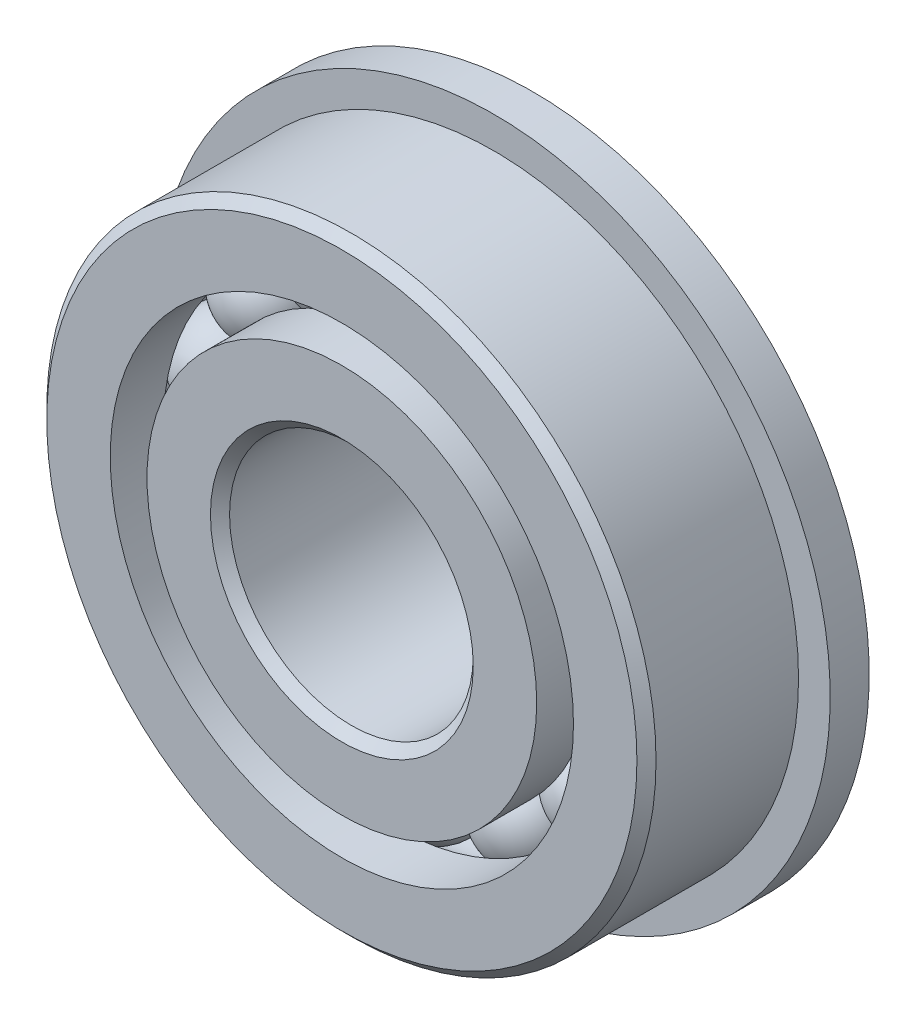
from build123d import *

# Parameters (mm, degrees)
SKETCH5_W         = 1.016
SKETCH5_H         = 1.901099286
CIRPATTERN1_COUNT = 14


with BuildPart() as part:
    # Sketch1 → Revolve1 (revolve)
    with BuildSketch(Plane(origin=(0, 0, 0), x_dir=(0, 0, -1), z_dir=(1, 0, 0))):
        with BuildLine():
            Line((2.24028, 7.9375), (-2.24028, 7.9375))
            Line((-2.24028, 7.9375), (-2.4892, 7.68858))
            Line((-2.4892, 7.68858), (-2.4892, 6.035221429))
            Line((-2.4892, 6.035221429), (-1.106311111, 6.035221429))
            ThreePointArc((-1.106311111, 6.035221429), (0, 6.76179465), (1.106311111, 6.035221429))
            Line((1.106311111, 6.035221429), (2.4892, 6.035221429))
            Line((2.4892, 6.035221429), (2.4892, 7.68858))
            Line((2.4892, 7.68858), (2.24028, 7.9375))
        make_face()
    revolve(axis=Axis((0, 0, 2.4892), (0, 0, -1)))

    # Sketch5 → Revolve5 (revolve)
    with BuildSketch(Plane(origin=(0, 0, 0), x_dir=(0, 0, -1), z_dir=(1, 0, 0))):
        with Locations((1.9812, 7.812450357)):
            Rectangle(SKETCH5_W, SKETCH5_H)
    revolve(axis=Axis((0, 0, -2.4892), (0, 0, 1)))


with BuildPart() as body_2:
    # Sketch3 → Revolve3 (revolve)
    with BuildSketch(Plane(origin=(0, 0, 0), x_dir=(0, 0, -1), z_dir=(1, 0, 0))):
        with BuildLine():
            Line((-1.106311111, 5.077278571), (-2.4892, 5.077278571))
            Line((-2.4892, 5.077278571), (-2.4892, 3.42392))
            Line((-2.4892, 3.42392), (-2.24028, 3.175))
            Line((-2.24028, 3.175), (2.24028, 3.175))
            Line((2.24028, 3.175), (2.4892, 3.42392))
            Line((2.4892, 3.42392), (2.4892, 5.077278571))
            Line((2.4892, 5.077278571), (1.106311111, 5.077278571))
            ThreePointArc((1.106311111, 5.077278571), (0, 4.35070535), (-1.106311111, 5.077278571))
        make_face()
    revolve(axis=Axis((0, 0, 2.4892), (0, 0, -1)))


with BuildPart() as body_3:
    # Sketch4 → Revolve4 (revolve)
    with BuildSketch(Plane(origin=(0, 0, 0), x_dir=(0, 0, -1), z_dir=(1, 0, 0))):
        with BuildLine():
            Line((-1.20554465, 5.55625), (1.20554465, 5.55625))
            ThreePointArc((1.20554465, 5.55625), (0, 6.76179465), (-1.20554465, 5.55625))
        make_face()
    revolve(axis=Axis((0, 5.55625, 1.20554465), (0, 0, -1)))


with BuildPart() as cirpattern1_1:
    # CirPattern1: pattern copy
    add(body_3.part.rotate(Axis((0, 0, -2.4892), (0, 0, 1)), 1 * 360 / CIRPATTERN1_COUNT))


with BuildPart() as cirpattern1_2:
    # CirPattern1: pattern copy
    add(body_3.part.rotate(Axis((0, 0, -2.4892), (0, 0, 1)), 2 * 360 / CIRPATTERN1_COUNT))


with BuildPart() as cirpattern1_3:
    # CirPattern1: pattern copy
    add(body_3.part.rotate(Axis((0, 0, -2.4892), (0, 0, 1)), 3 * 360 / CIRPATTERN1_COUNT))


with BuildPart() as cirpattern1_4:
    # CirPattern1: pattern copy
    add(body_3.part.rotate(Axis((0, 0, -2.4892), (0, 0, 1)), 4 * 360 / CIRPATTERN1_COUNT))


with BuildPart() as cirpattern1_5:
    # CirPattern1: pattern copy
    add(body_3.part.rotate(Axis((0, 0, -2.4892), (0, 0, 1)), 5 * 360 / CIRPATTERN1_COUNT))


with BuildPart() as cirpattern1_6:
    # CirPattern1: pattern copy
    add(body_3.part.rotate(Axis((0, 0, -2.4892), (0, 0, 1)), 6 * 360 / CIRPATTERN1_COUNT))


with BuildPart() as cirpattern1_7:
    # CirPattern1: pattern copy
    add(body_3.part.rotate(Axis((0, 0, -2.4892), (0, 0, 1)), 7 * 360 / CIRPATTERN1_COUNT))


with BuildPart() as cirpattern1_8:
    # CirPattern1: pattern copy
    add(body_3.part.rotate(Axis((0, 0, -2.4892), (0, 0, 1)), 8 * 360 / CIRPATTERN1_COUNT))


with BuildPart() as cirpattern1_9:
    # CirPattern1: pattern copy
    add(body_3.part.rotate(Axis((0, 0, -2.4892), (0, 0, 1)), 9 * 360 / CIRPATTERN1_COUNT))


with BuildPart() as cirpattern1_10:
    # CirPattern1: pattern copy
    add(body_3.part.rotate(Axis((0, 0, -2.4892), (0, 0, 1)), 10 * 360 / CIRPATTERN1_COUNT))


with BuildPart() as cirpattern1_11:
    # CirPattern1: pattern copy
    add(body_3.part.rotate(Axis((0, 0, -2.4892), (0, 0, 1)), 11 * 360 / CIRPATTERN1_COUNT))


with BuildPart() as cirpattern1_12:
    # CirPattern1: pattern copy
    add(body_3.part.rotate(Axis((0, 0, -2.4892), (0, 0, 1)), 12 * 360 / CIRPATTERN1_COUNT))


with BuildPart() as cirpattern1_13:
    # CirPattern1: pattern copy
    add(body_3.part.rotate(Axis((0, 0, -2.4892), (0, 0, 1)), 13 * 360 / CIRPATTERN1_COUNT))


solid = Compound([part.part, body_2.part, body_3.part, cirpattern1_1.part, cirpattern1_2.part, cirpattern1_3.part, cirpattern1_4.part, cirpattern1_5.part, cirpattern1_6.part, cirpattern1_7.part, cirpattern1_8.part, cirpattern1_9.part, cirpattern1_10.part, cirpattern1_11.part, cirpattern1_12.part, cirpattern1_13.part])
